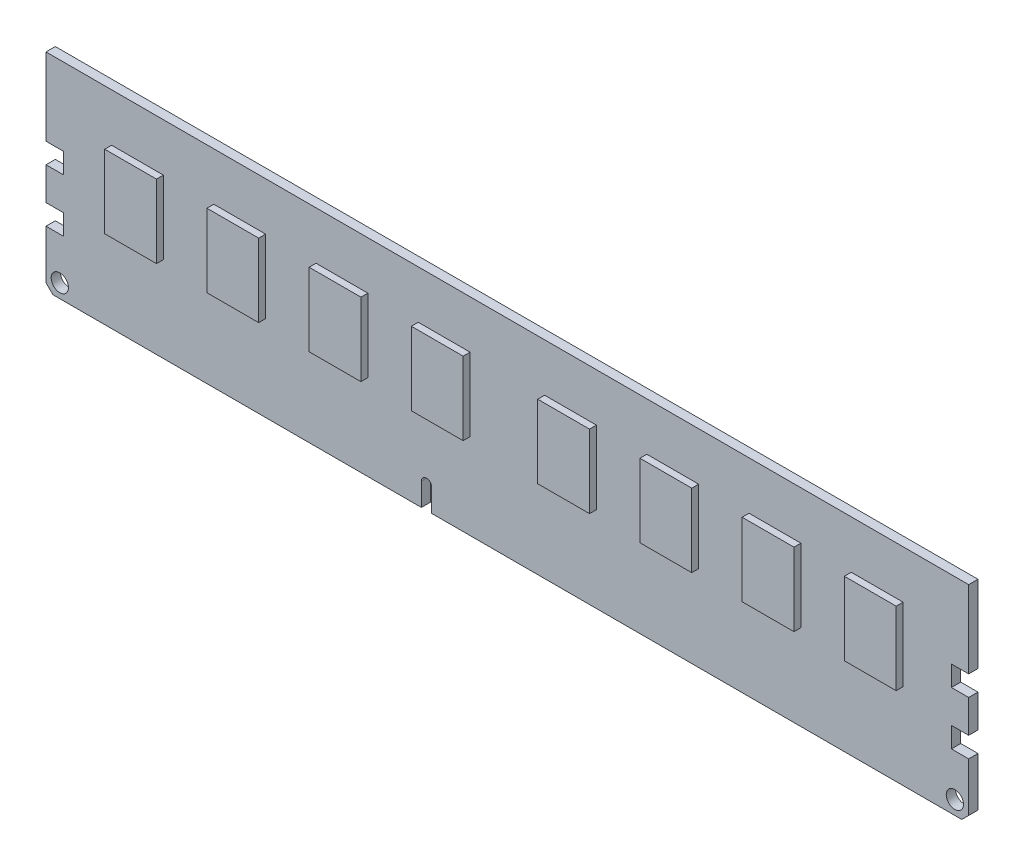
from build123d import *

# Parameters (mm, degrees)
SKETCH1_R           = 1.25
BOSS_EXTRUDE1_DEPTH = 0.675
SKETCH2_W           = 7.5
SKETCH2_H           = 10.6
BOSS_EXTRUDE2_DEPTH = 1
CUT_EXTRUDE1_DEPTH  = 3.35


with BuildPart() as part:
    # Sketch1 → Boss-Extrude1 (new body)
    with BuildSketch(Plane.XY):
        Polygon((-66.8, 18.75), (-64.3, 18.75), (-64.3, 15.8), (-66.8, 15.8), (-66.8, 11.05), (-64.3, 11.05), (-64.3, 8.1), (-66.8, 8.1), (-66.8, 1), (-65.8, 0), (0, 0), (0, 29.95), (-66.8, 29.95), align=None)
        with Locations((-64.8, 2)):
            Circle(SKETCH1_R, mode=Mode.SUBTRACT)
    extrude(amount=BOSS_EXTRUDE1_DEPTH)

    # Sketch2 → Boss-Extrude2 (add)
    with BuildSketch(Plane.XY.offset(0.675)):
        with Locations((-53.55, 17.7)):
            Rectangle(SKETCH2_W, SKETCH2_H)
        with Locations((-38.75, 17.7)):
            Rectangle(SKETCH2_W, SKETCH2_H)
        with Locations((-23.95, 17.7)):
            Rectangle(SKETCH2_W, SKETCH2_H)
        with Locations((-9.15, 17.7)):
            Rectangle(SKETCH2_W, SKETCH2_H)
    extrude(amount=BOSS_EXTRUDE2_DEPTH)

    # Mirror1: part across plane


with BuildPart() as part_1:
    add(part.part)
    add(part.part.mirror(Plane.XY))

    # Mirror2: part across plane


with BuildPart() as part_2:
    add(part_1.part)
    add(part_1.part.mirror(Plane(origin=(0, 0, 0), x_dir=(0, 0, 1), z_dir=(1, 0, 0))))

    # Sketch3 → Cut-Extrude1 (cut, through all)
    with BuildSketch(Plane.XY.offset(0.675)):
        with BuildLine():
            Line((-12.45, 0), (-12.45, 3.3))
            ThreePointArc((-12.45, 3.3), (-11.7, 4.05), (-10.95, 3.3))
            Line((-10.95, 3.3), (-10.95, 0))
            Line((-10.95, 0), (-12.45, 0))
        make_face()
    extrude(amount=-CUT_EXTRUDE1_DEPTH, mode=Mode.SUBTRACT)


solid = part_2.part
